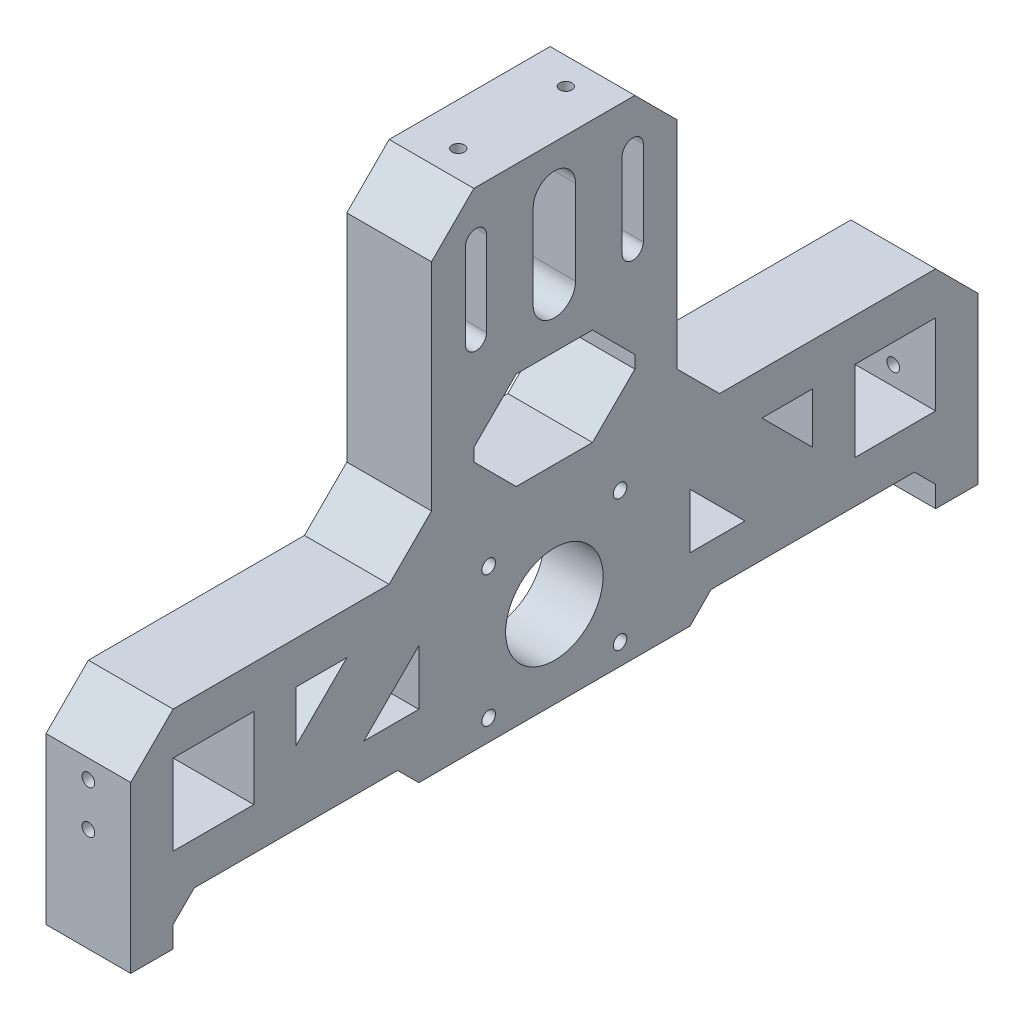
from build123d import *

# Parameters (mm, degrees)
SKETCH1_W           = 100
SKETCH1_H           = 120
BOSS_EXTRUDE1_DEPTH = 20
SKETCH2_W           = 19.05
SKETCH2_H           = 19.05
CUT_EXTRUDE1_DEPTH  = 20
SKETCH3_R           = 1.5
CUT_EXTRUDE2_DEPTH  = 20
SKETCH5_R           = 11.5
SKETCH5_R_2         = 1.6
CUT_EXTRUDE3_DEPTH  = 20
SKETCH6_W           = 44
SKETCH6_H           = 44
MOTOR_INDENT_DEPTH  = 6
BEARING_BLOCK_DEPTH = 21
SKETCH8_W           = 71
SKETCH8_H           = 70.95
CUT_EXTRUDE6_DEPTH  = 21
CHAMFER1_SIZE       = 10
SKETCH10_W          = 58
SKETCH10_H          = 10
CUT_EXTRUDE7_DEPTH  = 21
CHAMFER2_SIZE       = 5
CHAMFER3_SIZE       = 4.5
SKETCH11_R          = 1.45
CUT_EXTRUDE8_DEPTH  = 10
SKETCH12_W          = 38
SKETCH12_H          = 23
CUT_EXTRUDE9_DEPTH  = 21
CHAMFER4_SIZE       = 10
CUT_EXTRUDE10_DEPTH = 21
SKETCH14_W          = 64
SKETCH14_H          = 5
CUT_EXTRUDE11_DEPTH = 21


with BuildPart() as part:
    # Sketch1 → Boss-Extrude1 (new body)
    with BuildSketch(Plane(origin=(0, 0, 0), x_dir=(0, 0, -1), z_dir=(1, 0, 0))):
        with Locations((-50, 60)):
            Rectangle(SKETCH1_W, SKETCH1_H)
    boss_extrude1 = extrude(amount=BOSS_EXTRUDE1_DEPTH)

    # Sketch2 → Cut-Extrude1 (cut)
    with BuildSketch(Plane(origin=(20, 0, 0), x_dir=(0, 0, -1), z_dir=(1, 0, 0))):
        with Locations((-80.475, 29.525)):
            Rectangle(SKETCH2_W, SKETCH2_H)
    cut_extrude1 = extrude(amount=-CUT_EXTRUDE1_DEPTH, mode=Mode.SUBTRACT)

    # Sketch3 → Cut-Extrude2 (cut)
    with BuildSketch(Plane.XY.offset(100)):
        with Locations((10, 34.605)):
            Circle(SKETCH3_R)
        with Locations((10, 24.445)):
            Circle(SKETCH3_R)
    cut_extrude2 = extrude(amount=-CUT_EXTRUDE2_DEPTH, mode=Mode.SUBTRACT)

    # Mirror1: Boss-Extrude1, Cut-Extrude1, Cut-Extrude2 across plane
    add(boss_extrude1.mirror(Plane(origin=(20, 0, 0), x_dir=(1, 0, 0), z_dir=(0, 0, 1))))
    add(cut_extrude1.mirror(Plane(origin=(20, 0, 0), x_dir=(1, 0, 0), z_dir=(0, 0, 1))), mode=Mode.SUBTRACT)
    add(cut_extrude2.mirror(Plane(origin=(20, 0, 0), x_dir=(1, 0, 0), z_dir=(0, 0, 1))), mode=Mode.SUBTRACT)

    # Sketch5 → Cut-Extrude3 (cut)
    with BuildSketch(Plane(origin=(20, 0, 0), x_dir=(0, 0, -1), z_dir=(1, 0, 0))):
        with Locations((0, 25.5)):
            Circle(SKETCH5_R)
        with Locations((-15.5, 41)):
            Circle(SKETCH5_R_2)
        with Locations((15.5, 41)):
            Circle(SKETCH5_R_2)
        with Locations((15.5, 10)):
            Circle(SKETCH5_R_2)
        with Locations((-15.5, 10)):
            Circle(SKETCH5_R_2)
    extrude(amount=-CUT_EXTRUDE3_DEPTH, mode=Mode.SUBTRACT)

    # Sketch6 → Motor indent (cut)
    with BuildSketch(Plane.ZY):
        with Locations((0, 25.5)):
            Rectangle(SKETCH6_W, SKETCH6_H)
    extrude(amount=-MOTOR_INDENT_DEPTH, mode=Mode.SUBTRACT)

    # Sketch7 → Bearing Block (cut, through all)
    with BuildSketch(Plane.ZY):
        with BuildLine():
            Line((5, 109.05), (5, 89.05))
            ThreePointArc((5, 89.05), (0, 84.05), (-5, 89.05))
            Line((-5, 89.05), (-5, 109.05))
            ThreePointArc((-5, 109.05), (0, 114.05), (5, 109.05))
        make_face()
        with BuildLine():
            Line((-16, 109.05), (-16, 89.05))
            ThreePointArc((-16, 89.05), (-18.5, 86.55), (-21, 89.05))
            Line((-21, 89.05), (-21, 109.05))
            ThreePointArc((-21, 109.05), (-18.5, 111.55), (-16, 109.05))
        make_face()
        with BuildLine():
            Line((16, 109.05), (16, 89.05))
            ThreePointArc((16, 89.05), (18.5, 86.55), (21, 89.05))
            Line((21, 89.05), (21, 109.05))
            ThreePointArc((21, 109.05), (18.5, 111.55), (16, 109.05))
        make_face()
    extrude(amount=-BEARING_BLOCK_DEPTH, mode=Mode.SUBTRACT)

    # Sketch8 → Cut-Extrude6 (cut, through all)
    with BuildSketch(Plane(origin=(20, 0, 0), x_dir=(0, 0, -1), z_dir=(1, 0, 0))):
        with Locations((-64.5, 84.525)):
            Rectangle(SKETCH8_W, SKETCH8_H)
        with Locations((64.5, 84.525)):
            Rectangle(SKETCH8_W, SKETCH8_H)
    extrude(amount=-CUT_EXTRUDE6_DEPTH, mode=Mode.SUBTRACT)

    # Chamfer1
    chamfer1_edges = [part.edges().sort_by_distance(p)[0] for p in [
        (10, 120, 29),
        (10, 49.05, 29),
        (10, 49.05, 100),
        (10, 49.05, -100),
        (10, 49.05, -29),
        (10, 120, -29),
    ]]
    chamfer(chamfer1_edges, length=CHAMFER1_SIZE)

    # Sketch10 → Cut-Extrude7 (cut, through all)
    with BuildSketch(Plane.ZY):
        with Locations((-61, 5)):
            Rectangle(SKETCH10_W, SKETCH10_H)
        with Locations((61, 5)):
            Rectangle(SKETCH10_W, SKETCH10_H)
    extrude(amount=-CUT_EXTRUDE7_DEPTH, mode=Mode.SUBTRACT)

    # Chamfer2
    chamfer2_edges = [part.edges().sort_by_distance(p)[0] for p in [
        (10, 10, -90),
        (10, 10, -32),
        (10, 10, 32),
        (10, 10, 90),
    ]]
    chamfer(chamfer2_edges, length=CHAMFER2_SIZE)

    # Chamfer3
    chamfer3_edges = [part.edges().sort_by_distance(p)[0] for p in [
        (3, 47.5, 22),
        (3, 3.5, 22),
        (3, 3.5, -22),
        (3, 47.5, -22),
    ]]
    chamfer(chamfer3_edges, length=CHAMFER3_SIZE)

    # Sketch11 → Cut-Extrude8 (cut)
    with BuildSketch(Plane(origin=(0, 120, 0), x_dir=(1, 0, 0), z_dir=(0, 1, 0))):
        with Locations((10, -12.7)):
            Circle(SKETCH11_R)
        with Locations((10, 12.7)):
            Circle(SKETCH11_R)
    extrude(amount=-CUT_EXTRUDE8_DEPTH, mode=Mode.SUBTRACT)

    # Sketch12 → Cut-Extrude9 (cut, through all)
    with BuildSketch(Plane(origin=(20, 0, 0), x_dir=(0, 0, -1), z_dir=(1, 0, 0))):
        with Locations((0, 65.55)):
            Rectangle(SKETCH12_W, SKETCH12_H)
    extrude(amount=-CUT_EXTRUDE9_DEPTH, mode=Mode.SUBTRACT)

    # Chamfer4
    chamfer4_edges = [part.edges().sort_by_distance(p)[0] for p in [
        (10, 54.05, 19),
        (10, 77.05, 19),
        (10, 77.05, -19),
        (10, 54.05, -19),
    ]]
    chamfer(chamfer4_edges, length=CHAMFER4_SIZE)

    # Sketch13 → Cut-Extrude10 (cut, through all)
    with BuildSketch(Plane.ZY):
        Polygon((-49, 39.05), (-60.95, 27.1), (-60.95, 39.05), align=None)
        Polygon((-32, 33), (-45, 20), (-32, 20), align=None)
    cut_extrude10 = extrude(amount=-CUT_EXTRUDE10_DEPTH, mode=Mode.SUBTRACT)

    # Mirror2: Cut-Extrude10 across plane
    add(cut_extrude10.mirror(Plane.XY), mode=Mode.SUBTRACT)

    # Sketch14 → Cut-Extrude11 (cut, through all)
    with BuildSketch(Plane(origin=(20, 0, 0), x_dir=(0, 0, -1), z_dir=(1, 0, 0))):
        with Locations((0, 2.5)):
            Rectangle(SKETCH14_W, SKETCH14_H)
    extrude(amount=-CUT_EXTRUDE11_DEPTH, mode=Mode.SUBTRACT)


solid = part.part
